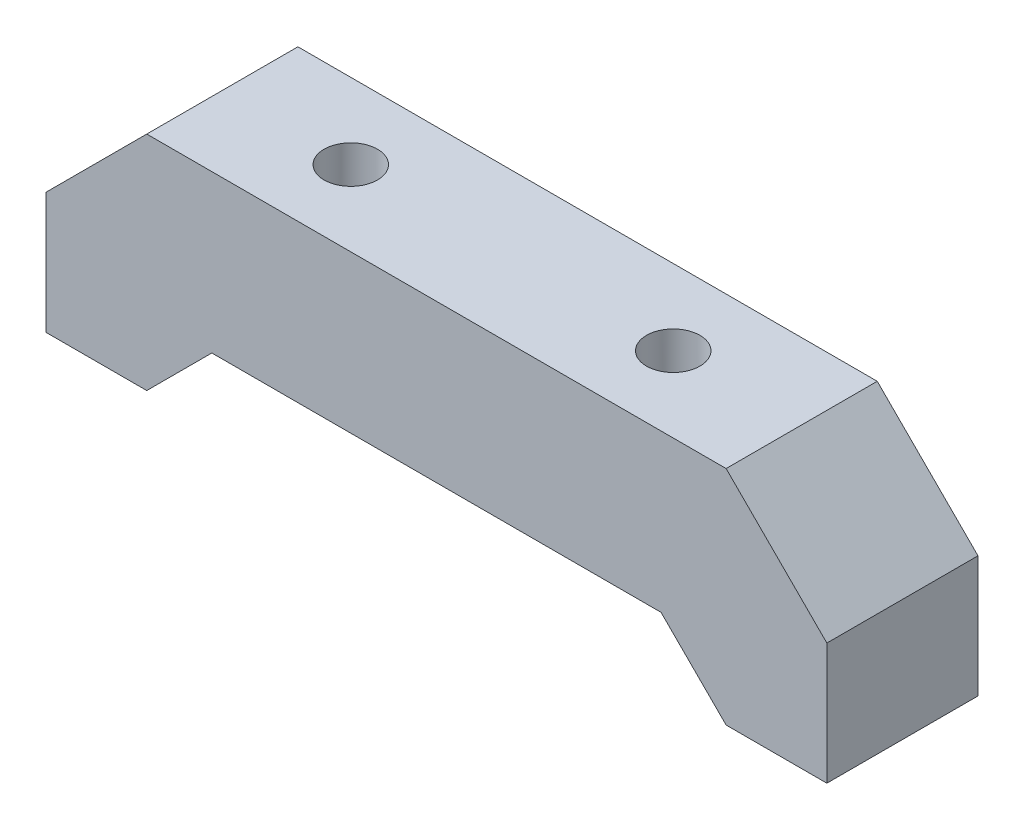
from build123d import *

# Parameters (mm, degrees)
SKETCH1_W           = 5
SKETCH1_H           = 10.590486739
BOSS_EXTRUDE1_DEPTH = 15
SKETCH2_R           = 2.65
CUT_EXTRUDE1_DEPTH  = 23.048277791
SKETCH3_R           = 4.5
CUT_EXTRUDE2_DEPTH  = 5


with BuildPart() as part:
    # Sketch1 → Boss-Extrude1 (new body)
    with BuildSketch(Plane.XY):
        Polygon((20.353041123, 8.769305032), (10.103041123, 8.769305032), (0.103041123, -1.230694968), (0.103041123, -13.278972759), (10.103041123, -13.278972759), (16.560832175, -6.821181707), (18.353041123, -6.821181707), (18.353041123, -1.821181707), (20.353041123, -1.821181707), align=None)
        Polygon((25.353041123, -1.821181707), (20.353041123, -1.821181707), (18.353041123, -1.821181707), (18.353041123, -6.821181707), (27.353041123, -6.821181707), (27.353041123, -1.821181707), align=None)
        with Locations((22.853041123, 3.474061663)):
            Rectangle(SKETCH1_W, SKETCH1_H)
        Polygon((52.353041123, 8.769305032), (25.353041123, 8.769305032), (25.353041123, -1.821181707), (27.353041123, -1.821181707), (27.353041123, -6.821181707), (50.353041123, -6.821181707), (50.353041123, -1.821181707), (52.353041123, -1.821181707), align=None)
        Polygon((57.353041123, -1.821181707), (52.353041123, -1.821181707), (50.353041123, -1.821181707), (50.353041123, -6.821181707), (59.353041123, -6.821181707), (59.353041123, -1.821181707), align=None)
        with Locations((54.853041123, 3.474061663)):
            Rectangle(SKETCH1_W, SKETCH1_H)
        Polygon((67.603041123, 8.769305032), (57.353041123, 8.769305032), (57.353041123, -1.821181707), (59.353041123, -1.821181707), (59.353041123, -6.821181707), (61.145250072, -6.821181707), (67.603041123, -13.278972759), (77.603041123, -13.278972759), (77.603041123, -1.230694968), align=None)
    extrude(amount=BOSS_EXTRUDE1_DEPTH)

    # Sketch2 → Cut-Extrude1 (cut, through all)
    with BuildSketch(Plane(origin=(0, 8.769305032, 0), x_dir=(1, 0, 0), z_dir=(0, 1, 0))):
        with Locations((22.853041123, -7.5)):
            Circle(SKETCH2_R)
        with Locations((54.853041123, -7.5)):
            Circle(SKETCH2_R)
    extrude(amount=-CUT_EXTRUDE1_DEPTH, mode=Mode.SUBTRACT)

    # Sketch3 → Cut-Extrude2 (cut)
    with BuildSketch(Plane.XZ.offset(6.821181707)):
        with Locations((22.853041123, 7.5)):
            Circle(SKETCH3_R)
        with Locations((54.853041123, 7.5)):
            Circle(SKETCH3_R)
    extrude(amount=-CUT_EXTRUDE2_DEPTH, mode=Mode.SUBTRACT)


solid = part.part
